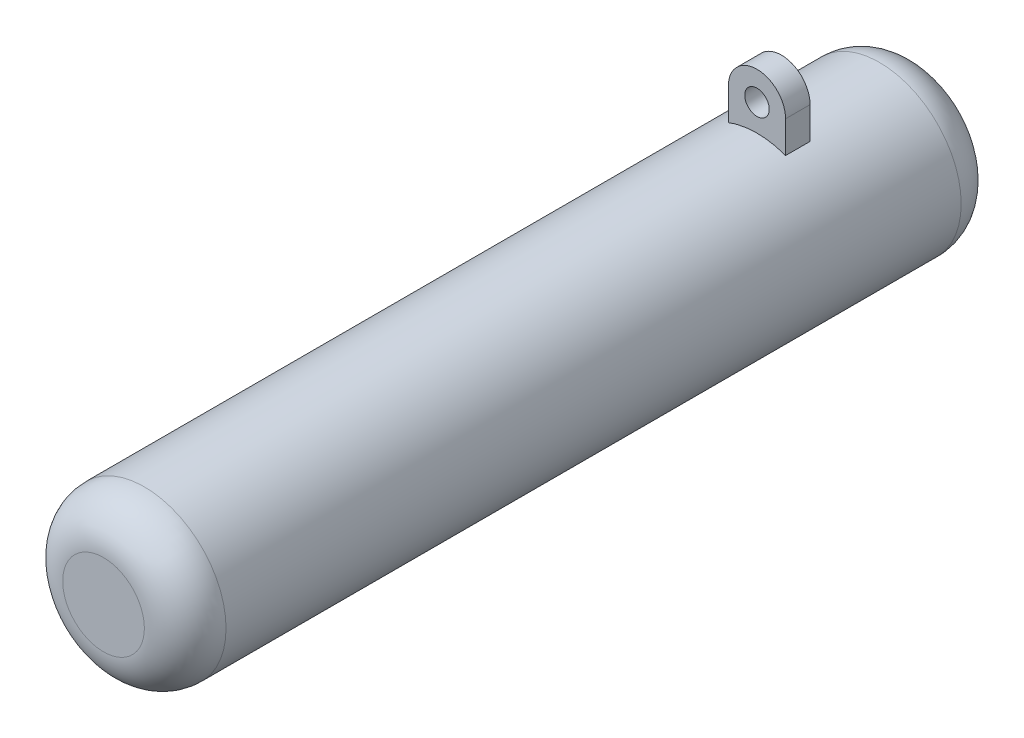
from build123d import *

# Parameters (mm, degrees)
SKETCH1_R           = 10
BOSS_EXTRUDE1_DEPTH = 100
FILLET1_R           = 5
SKETCH2_R           = 1.5
BOSS_EXTRUDE2_DEPTH = 3


with BuildPart() as part:
    # Sketch1 → Boss-Extrude1 (new body)
    with BuildSketch(Plane.XY):
        Circle(SKETCH1_R)
    extrude(amount=BOSS_EXTRUDE1_DEPTH)

    # Fillet1
    fillet1_edges = [part.edges().sort_by_distance(p)[0] for p in [
        (-10, 0, 0),
        (-10, 0, 100),
    ]]
    fillet(fillet1_edges, radius=FILLET1_R)


with BuildPart() as body_2:
    # Sketch2 → Boss-Extrude2 (new body)
    with BuildSketch(Plane.XY.offset(20)):
        with BuildLine():
            Line((3.5, 9.367496998), (3.5, 13.270248109))
            ThreePointArc((3.5, 13.270248109), (0, 16.770248109), (-3.5, 13.270248109))
            Line((-3.5, 13.270248109), (-3.5, 9.367496998))
            ThreePointArc((-3.5, 9.367496998), (0, 10), (3.5, 9.367496998))
        make_face()
        with Locations((0, 13.270248109)):
            Circle(SKETCH2_R, mode=Mode.SUBTRACT)
    extrude(amount=-BOSS_EXTRUDE2_DEPTH)


solid = Compound([part.part, body_2.part])
